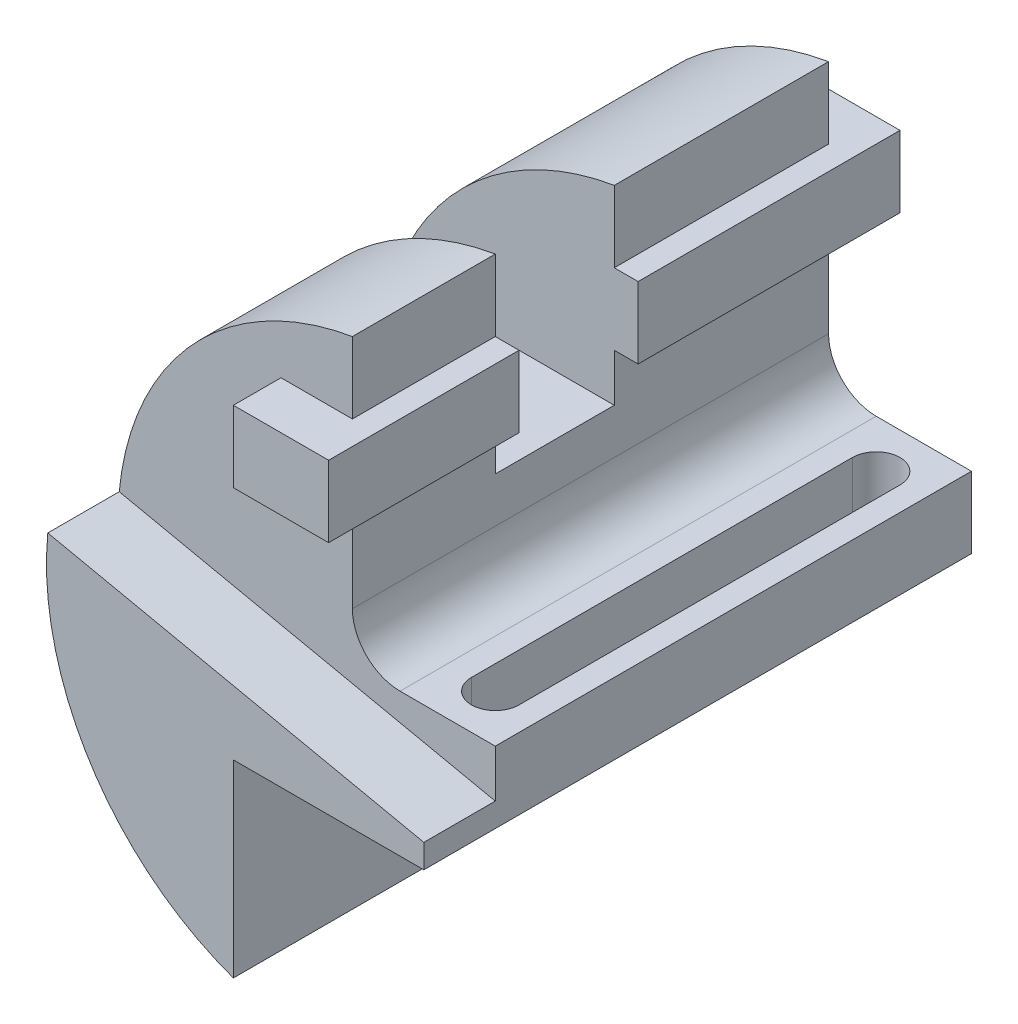
from build123d import *

# Parameters (mm, degrees)
BOSS_EXTRUDE1_DEPTH     = 100
BOSS_EXTRUDE2_DEPTH     = 15
SKETCH3_W               = 25
SKETCH3_H               = 40
CUT_EXTRUDE1_DEPTH      = 21
CUT_EXTRUDE1_DEPTH_BACK = 60.25
SKETCH4_W               = 20
SKETCH4_H               = 15
BOSS_EXTRUDE3_DEPTH     = 55
SKETCH5_W               = 20
SKETCH5_H               = 15
BOSS_EXTRUDE4_DEPTH     = 40
CUT_EXTRUDE2_DEPTH      = 60.5
CUT_EXTRUDE2_DEPTH_BACK = 55.672438422


with BuildPart() as part:
    # Sketch1 → Boss-Extrude1 (new body)
    with BuildSketch(Plane.XY):
        with BuildLine():
            Line((-10, 58.400021404), (-10, 43.400021404))
            Line((-10, 43.400021404), (-25, 43.400021404))
            Line((-25, 43.400021404), (-25, 28.400021404))
            Line((-25, 28.400021404), (-10, 28.400021404))
            Line((-10, 28.400021404), (-10, 8.900021404))
            ThreePointArc((-10, 8.900021404), (-7.071067812, 1.828953592), (0, -1.099978596))
            Line((0, -1.099978596), (20, -1.099978596))
            Line((20, -1.099978596), (20, -16.099978596))
            Line((20, -16.099978596), (-20, -16.099978596))
            Line((-20, -16.099978596), (-20, -55.772417018))
            ThreePointArc((-20, -55.772417018), (-59.024032595, 5.169726898), (-10, 58.400021404))
        make_face()
    extrude(amount=-BOSS_EXTRUDE1_DEPTH)

    # Sketch2 → Boss-Extrude2 (add)
    with BuildSketch(Plane.XY):
        with BuildLine():
            Line((20, -11.099978596), (-58.976442171, 5.686982405))
            ThreePointArc((-58.976442171, 5.686982405), (-50.036327292, -31.732135938), (-20, -55.772417018))
            Line((-20, -55.772417018), (-20, -16.099978596))
            Line((-20, -16.099978596), (20, -16.099978596))
            Line((20, -16.099978596), (20, -11.099978596))
        make_face()
    extrude(amount=BOSS_EXTRUDE2_DEPTH)

    # Sketch3 → Cut-Extrude1 (cut, two sides)
    with BuildSketch(Plane(origin=(0, 0, 0), x_dir=(0, 0, -1), z_dir=(1, 0, 0))) as cut_extrude1_sk:
        with Locations((42.5, 38.400021404)):
            Rectangle(SKETCH3_W, SKETCH3_H)
    extrude(amount=CUT_EXTRUDE1_DEPTH, mode=Mode.SUBTRACT)
    extrude(cut_extrude1_sk.sketch, amount=-CUT_EXTRUDE1_DEPTH_BACK, mode=Mode.SUBTRACT)

    # Sketch4 → Boss-Extrude3 (add)
    with BuildSketch(Plane.XY.offset(-55)):
        with Locations((-15, 35.900021404)):
            Rectangle(SKETCH4_W, SKETCH4_H)
    extrude(amount=-BOSS_EXTRUDE3_DEPTH)

    # Sketch5 → Boss-Extrude4 (add)
    with BuildSketch(Plane(origin=(0, 0, -30), x_dir=(-1, 0, 0), z_dir=(0, 0, -1))):
        with Locations((15, 35.900021404)):
            Rectangle(SKETCH5_W, SKETCH5_H)
    extrude(amount=-BOSS_EXTRUDE4_DEPTH)

    # Sketch6 → Cut-Extrude2 (cut, two sides)
    with BuildSketch(Plane(origin=(0, -1.099978596, 0), x_dir=(1, 0, 0), z_dir=(0, 1, 0))) as cut_extrude2_sk:
        with BuildLine():
            Line((15, 90), (15, 10))
            ThreePointArc((15, 10), (10, 5), (5, 10))
            Line((5, 10), (5, 90))
            ThreePointArc((5, 90), (10, 95), (15, 90))
        make_face()
    extrude(amount=CUT_EXTRUDE2_DEPTH, mode=Mode.SUBTRACT)
    extrude(cut_extrude2_sk.sketch, amount=-CUT_EXTRUDE2_DEPTH_BACK, mode=Mode.SUBTRACT)


solid = part.part
